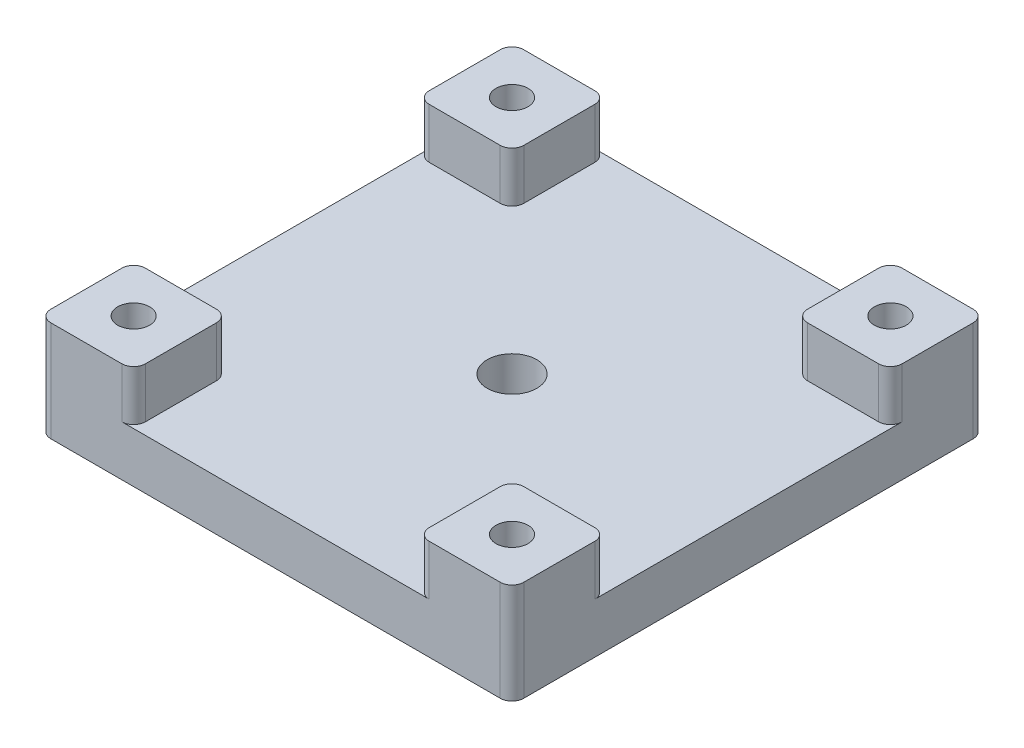
from build123d import *

# Parameters (mm, degrees)
SKETCH1_W           = 40
SKETCH1_H           = 40
BOSS_EXTRUDE1_DEPTH = 8.5
SKETCH2_R           = 1.3525
SKETCH2_R_2         = 2.1
CUT_EXTRUDE1_DEPTH  = 9.5
SKETCH3_R           = 3.5
CUT_EXTRUDE2_DEPTH  = 4.25
CUT_EXTRUDE3_DEPTH  = 4.25
FILLET1_R           = 1


with BuildPart() as part:
    # Sketch1 → Boss-Extrude1 (new body)
    with BuildSketch(Plane(origin=(0, 0, 0), x_dir=(1, 0, 0), z_dir=(0, 1, 0))):
        with Locations((20, 20)):
            Rectangle(SKETCH1_W, SKETCH1_H)
    extrude(amount=BOSS_EXTRUDE1_DEPTH)

    # Sketch2 → Cut-Extrude1 (cut, through all)
    with BuildSketch(Plane(origin=(0, 8.5, 0), x_dir=(1, 0, 0), z_dir=(0, 1, 0))):
        with Locations((4, 4)):
            Circle(SKETCH2_R)
        with Locations((36, 4)):
            Circle(SKETCH2_R)
        with Locations((36, 36)):
            Circle(SKETCH2_R)
        with Locations((4, 36)):
            Circle(SKETCH2_R)
        with Locations((20, 20)):
            Circle(SKETCH2_R_2)
    extrude(amount=-CUT_EXTRUDE1_DEPTH, mode=Mode.SUBTRACT)

    # Sketch3 → Cut-Extrude2 (cut)
    with BuildSketch(Plane(origin=(0, 8.5, 0), x_dir=(1, 0, 0), z_dir=(0, 1, 0))):
        with Locations((20, 20)):
            Circle(SKETCH3_R)
    extrude(amount=-CUT_EXTRUDE2_DEPTH, mode=Mode.SUBTRACT)

    # Sketch4 → Cut-Extrude3 (cut)
    with BuildSketch(Plane(origin=(0, 8.5, 0), x_dir=(1, 0, 0), z_dir=(0, 1, 0))):
        Polygon((0, 8), (8, 8), (8, 0), (32, 0), (32, 8), (40, 8), (40, 32), (32, 32), (32, 40), (8, 40), (8, 32), (0, 32), align=None)
    extrude(amount=-CUT_EXTRUDE3_DEPTH, mode=Mode.SUBTRACT)

    # Fillet1
    fillet1_edges = [part.edges().sort_by_distance(p)[0] for p in [
        (0, 4.25, -40),
        (40, 4.25, -40),
        (40, 4.25, 0),
        (0, 4.25, 0),
        (0, 6.375, -8),
        (0, 6.375, -32),
        (8, 6.375, -32),
        (8, 6.375, -40),
        (32, 6.375, -40),
        (32, 6.375, -32),
        (40, 6.375, -32),
        (40, 6.375, -8),
        (32, 6.375, -8),
        (32, 6.375, 0),
        (8, 6.375, 0),
        (8, 6.375, -8),
    ]]
    fillet(fillet1_edges, radius=FILLET1_R)


solid = part.part
